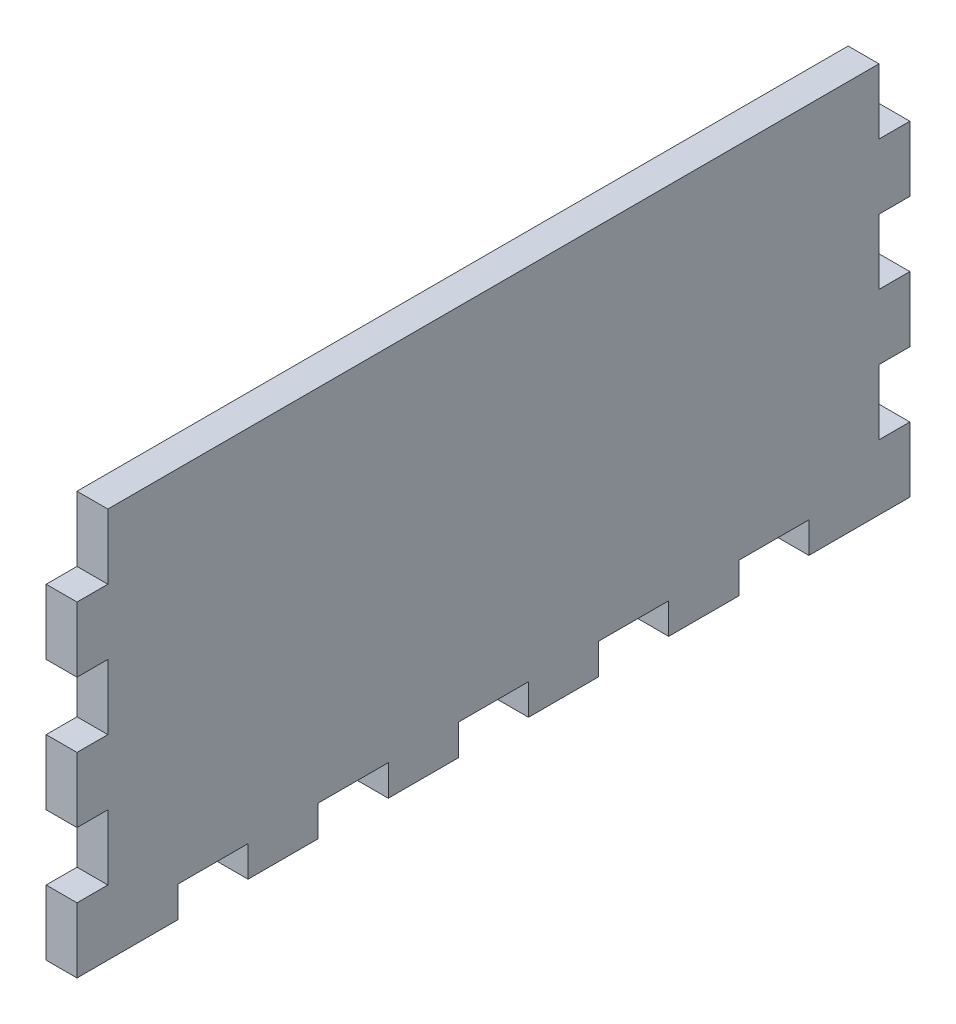
from build123d import *

# Parameters (mm, degrees)
ESTRUSIONE_ESTRUSIONE3_DEPTH = 1.5


with BuildPart() as part:
    # Schizzo1 → Estrusione-Estrusione3 (new body, symmetric)
    with BuildSketch(Plane(origin=(0, 0, 0), x_dir=(0, 0, -1), z_dir=(1, 0, 0))):
        Polygon((-40.5, -20.5), (-37.5, -20.5), (-30.681818182, -20.5), (-30.681818182, -17.5), (-23.863636364, -17.5), (-23.863636364, -20.5), (-17.045454545, -20.5), (-17.045454545, -17.5), (-10.227272727, -17.5), (-10.227272727, -20.5), (-3.409090909, -20.5), (-3.409090909, -17.5), (3.409090909, -17.5), (3.409090909, -20.5), (10.227272727, -20.5), (10.227272727, -17.5), (17.045454545, -17.5), (17.045454545, -20.5), (23.863636364, -20.5), (23.863636364, -17.5), (30.681818182, -17.5), (30.681818182, -20.5), (37.5, -20.5), (40.5, -20.5), (40.5, -14.166666667), (37.5, -14.166666667), (37.5, -7.833333333), (40.5, -7.833333333), (40.5, -1.5), (37.5, -1.5), (37.5, 4.833333333), (40.5, 4.833333333), (40.5, 11.166666667), (37.5, 11.166666667), (37.5, 17.5), (-37.5, 17.5), (-37.5, 11.166666667), (-40.5, 11.166666667), (-40.5, 4.833333333), (-37.5, 4.833333333), (-37.5, -1.5), (-40.5, -1.5), (-40.5, -7.833333333), (-37.5, -7.833333333), (-37.5, -14.166666667), (-40.5, -14.166666667), align=None)
    extrude(amount=ESTRUSIONE_ESTRUSIONE3_DEPTH, both=True)


solid = part.part
